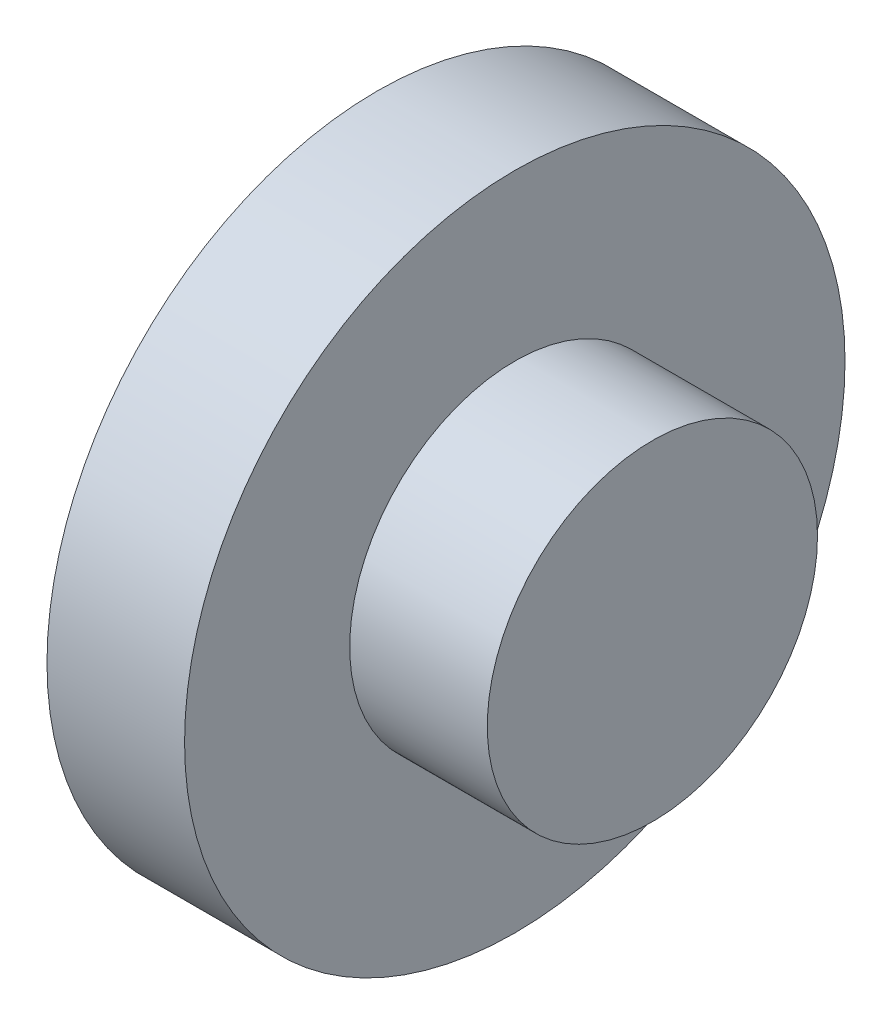
from build123d import *

# Parameters (mm, degrees)
SKETCH_1_R      = 24
EXTRUDE_1_DEPTH = 10
SKETCH_2_R      = 12
EXTRUDE_2_DEPTH = 10


with BuildPart() as part:
    # 草图1 → 凸台-拉伸1 (new body)
    with BuildSketch(Plane(origin=(0, 0, 0), x_dir=(0, 0, -1), z_dir=(1, 0, 0))):
        Circle(SKETCH_1_R)
    extrude(amount=EXTRUDE_1_DEPTH)

    # 草图2 → 凸台-拉伸2 (add)
    with BuildSketch(Plane(origin=(10, 0, 0), x_dir=(0, 0, -1), z_dir=(1, 0, 0))):
        Circle(SKETCH_2_R)
    extrude(amount=EXTRUDE_2_DEPTH)


solid = part.part
